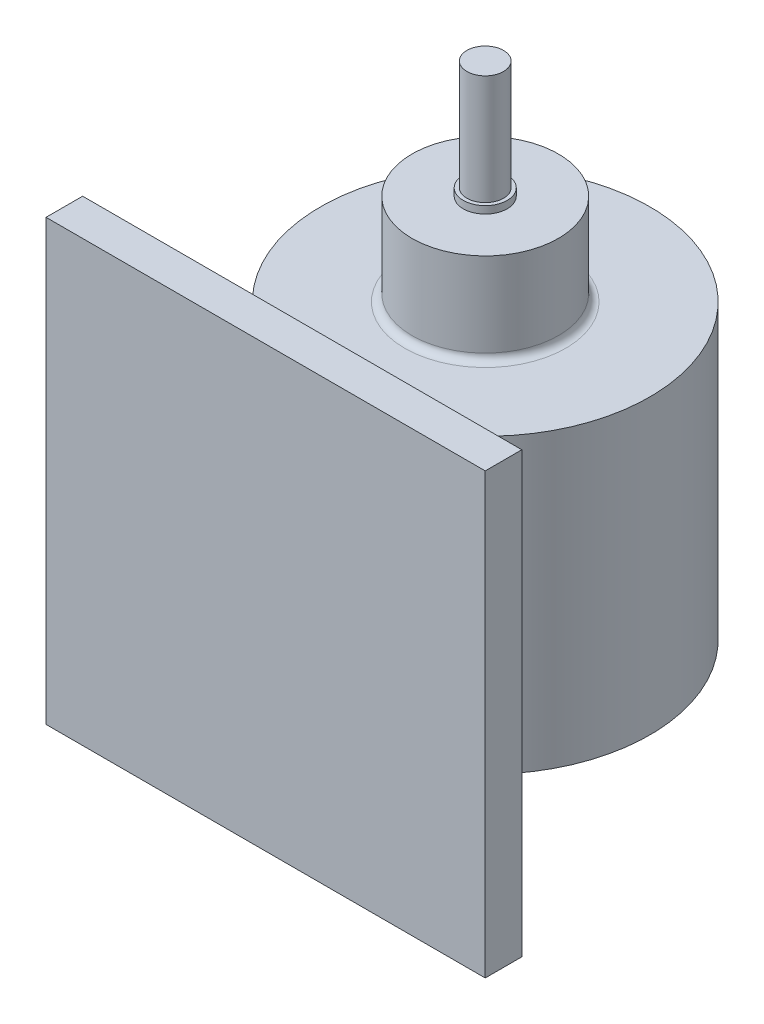
from build123d import *

# Parameters (mm, degrees)
SKETCH1_W           = 120
SKETCH1_H           = 120
BOSS_EXTRUDE1_DEPTH = 10
SKETCH2_R           = 45
BOSS_EXTRUDE2_DEPTH = 40
SKETCH3_W           = 10
SKETCH3_H           = 80
BOSS_EXTRUDE3_DEPTH = 50
SKETCH4_R           = 20
BOSS_EXTRUDE4_DEPTH = 25
FILLET1_R           = 2
SKETCH6_R           = 6
BOSS_EXTRUDE5_DEPTH = 2
SKETCH7_R           = 5
BOSS_EXTRUDE6_DEPTH = 30


with BuildPart() as part:
    # Sketch1 → Boss-Extrude1 (new body)
    with BuildSketch(Plane.XY):
        Rectangle(SKETCH1_W, SKETCH1_H)
    extrude(amount=BOSS_EXTRUDE1_DEPTH)

    # Sketch3 → Boss-Extrude3 (add)
    with BuildSketch(Plane(origin=(0, 0, 0), x_dir=(-1, 0, 0), z_dir=(0, 0, -1))):
        with Locations((-25, 0)):
            Rectangle(SKETCH3_W, SKETCH3_H)
        with Locations((25, 0)):
            Rectangle(SKETCH3_W, SKETCH3_H)
    extrude(amount=BOSS_EXTRUDE3_DEPTH)



with BuildPart() as body_2:
    # Sketch2 → Boss-Extrude2 (new body, symmetric)
    with BuildSketch(Plane(origin=(0, 0, 0), x_dir=(1, 0, 0), z_dir=(0, 1, 0))):
        with Locations((0, 50)):
            Circle(SKETCH2_R)
    extrude(amount=BOSS_EXTRUDE2_DEPTH, both=True)


with BuildPart() as part_1:
    add(part.part)

    add(body_2.part)  # Boss-Extrude4 merges body 2
    # Sketch4 → Boss-Extrude4 (add)
    with BuildSketch(Plane(origin=(0, 40, 0), x_dir=(1, 0, 0), z_dir=(0, 1, 0))):
        with Locations((0, 50)):
            Circle(SKETCH4_R)
    extrude(amount=BOSS_EXTRUDE4_DEPTH)

    # Fillet1
    fillet1_edges = [part_1.edges().sort_by_distance(p)[0] for p in [
        (-20, 40, -50),
    ]]
    fillet(fillet1_edges, radius=FILLET1_R)

    # Sketch6 → Boss-Extrude5 (add)
    with BuildSketch(Plane(origin=(0, 65, 0), x_dir=(1, 0, 0), z_dir=(0, 1, 0))):
        with Locations((0, 50)):
            Circle(SKETCH6_R)
    extrude(amount=BOSS_EXTRUDE5_DEPTH)

    # Sketch7 → Boss-Extrude6 (add)
    with BuildSketch(Plane(origin=(0, 67, 0), x_dir=(1, 0, 0), z_dir=(0, 1, 0))):
        with Locations((0, 50)):
            Circle(SKETCH7_R)
    extrude(amount=BOSS_EXTRUDE6_DEPTH)


solid = part_1.part
